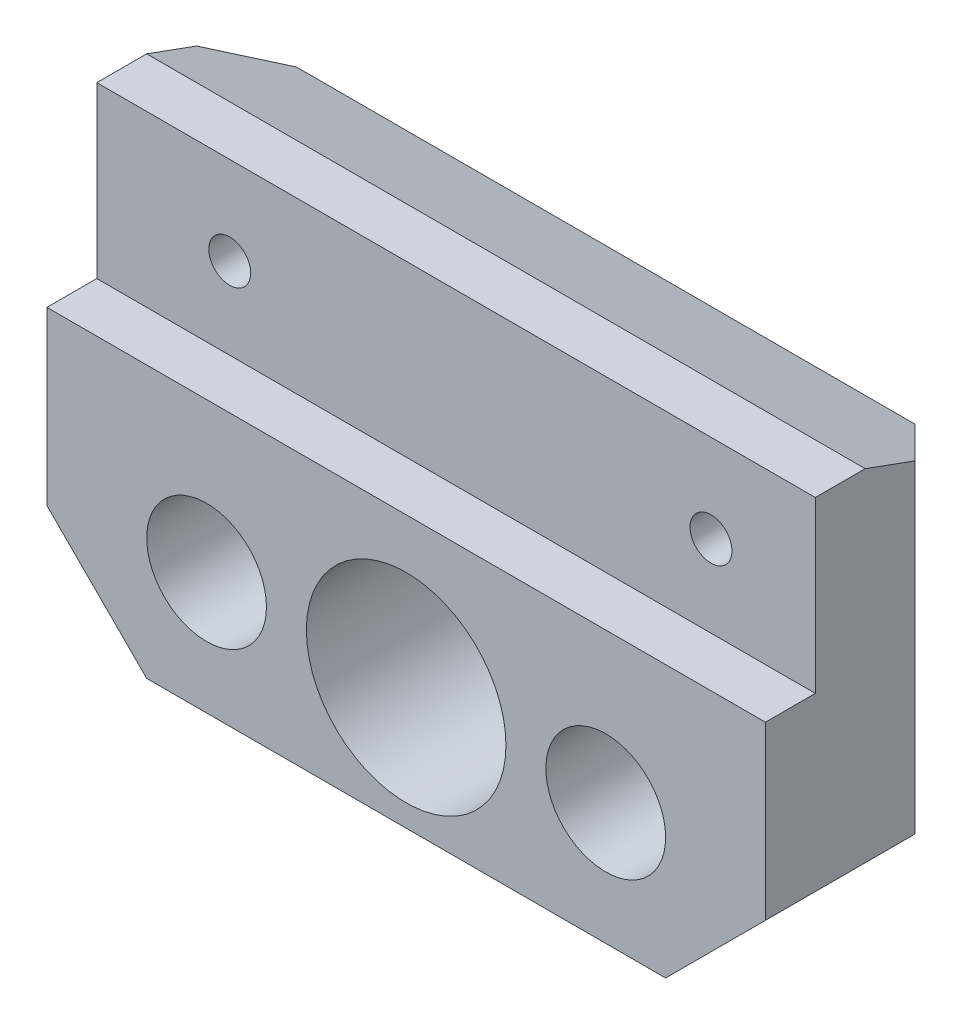
from build123d import *

# Parameters (mm, degrees)
SKIZZE1_W                       = 72
SKIZZE1_H                       = 44.2
SKIZZE1_R                       = 10
SKIZZE1_R_2                     = 6
AUFSATZ_LINEAR_AUSTRAGEN1_DEPTH = 20
FASE1_SIZE                      = 10
FASE2_SIZE                      = 10
FASE6_SIZE                      = 10
FASE6_SIZE2                     = 3.639702343
FASE7_SIZE                      = 5
SKIZZE3_W                       = 5
SKIZZE3_H                       = 17
SCHNITT_LINEAR_AUSTRAGEN1_DEPTH = 80
SKIZZE11_R                      = 12
SCHNITT_LINEAR_AUSTRAGEN2_DEPTH = 3.4
M5_GEWINDEBOHRUNG1_D            = 4.2
M5_GEWINDEBOHRUNG1_DEPTH        = 12
M5_GEWINDEBOHRUNG1_TIP          = 1.2618073


with BuildPart() as part:
    # Skizze1 → Aufsatz-Linear austragen1 (new body)
    with BuildSketch(Plane.XY):
        with Locations((53.961300324, 0)):
            Rectangle(SKIZZE1_W, SKIZZE1_H)
        with Locations((53.961300324, -9.9)):
            Circle(SKIZZE1_R, mode=Mode.SUBTRACT)
        with Locations((33.961300324, -9.9)):
            Circle(SKIZZE1_R_2, mode=Mode.SUBTRACT)
        with Locations((73.961300324, -9.9)):
            Circle(SKIZZE1_R_2, mode=Mode.SUBTRACT)
    extrude(amount=AUFSATZ_LINEAR_AUSTRAGEN1_DEPTH)

    # Fase1
    fase1_edges = [part.edges().sort_by_distance(p)[0] for p in [
        (17.961300324, -22.1, 10),
    ]]
    chamfer(fase1_edges, length=FASE1_SIZE)

    # Fase2
    fase2_edges = [part.edges().sort_by_distance(p)[0] for p in [
        (89.961300324, -22.1, 10),
    ]]
    chamfer(fase2_edges, length=FASE2_SIZE)

    # Fase6
    fase6_edges = [part.edges().sort_by_distance(p)[0] for p in [
        (53.961300324, 22.1, 0),
    ]]
    fase6_side = [part.faces().sort_by_distance(p)[0] for p in [
        (53.961300324, 22.1, 10),
    ]]
    chamfer(fase6_edges, length=FASE6_SIZE, length2=FASE6_SIZE2, reference=fase6_side[0])

    # Fase7
    fase7_edges = [part.edges().sort_by_distance(p)[0] for p in [
        (89.961300324, 3.180148829, 0),
        (17.961300324, 3.180148829, 0),
    ]]
    chamfer(fase7_edges, length=FASE7_SIZE)

    # Skizze3 → Schnitt-Linear austragen1 (cut)
    with BuildSketch(Plane.ZY.offset(-17.961300324)):
        with Locations((17.5, 13.6)):
            Rectangle(SKIZZE3_W, SKIZZE3_H)
    extrude(amount=-SCHNITT_LINEAR_AUSTRAGEN1_DEPTH, mode=Mode.SUBTRACT)

    # Skizze11 → Schnitt-Linear austragen2 (cut)
    with BuildSketch(Plane(origin=(0, 0, 0), x_dir=(-1, 0, 0), z_dir=(0, 0, -1))):
        with Locations((-53.961300324, -9.9)):
            Circle(SKIZZE11_R)
    extrude(amount=-SCHNITT_LINEAR_AUSTRAGEN2_DEPTH, mode=Mode.SUBTRACT)

    # M5 Gewindebohrung1
    with Locations(Plane.XY.offset(15)):
        with Locations((31.282727226, 13.273175205), (79.505567547, 13.273175205)):
            Hole(M5_GEWINDEBOHRUNG1_D / 2, depth=M5_GEWINDEBOHRUNG1_DEPTH)
            with Locations((0, 0, -(M5_GEWINDEBOHRUNG1_DEPTH + M5_GEWINDEBOHRUNG1_TIP / 2))):  # 118° drill point
                Cone(0, M5_GEWINDEBOHRUNG1_D / 2, M5_GEWINDEBOHRUNG1_TIP, mode=Mode.SUBTRACT)


solid = part.part
